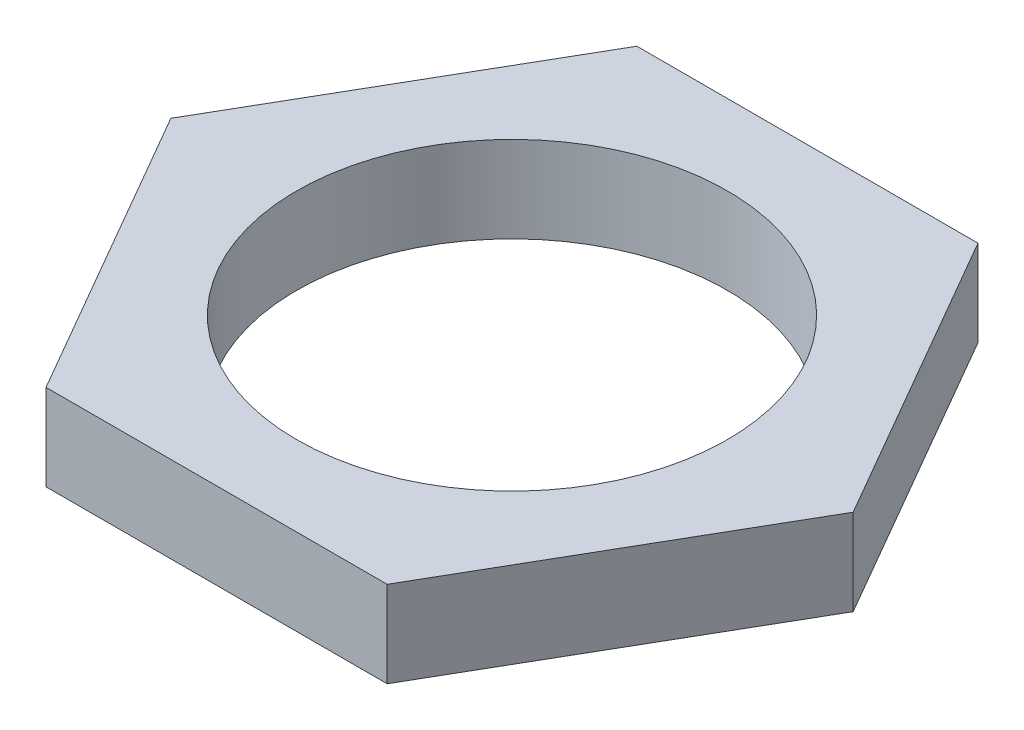
from build123d import *

# Parameters (mm, degrees)
SKETCH3_R           = 8.75
BOSS_EXTRUDE2_DEPTH = 3.5


with BuildPart() as part:
    # Sketch3 → Boss-Extrude2 (new body)
    with BuildSketch(Plane(origin=(0, 0, 0), x_dir=(1, 0, 0), z_dir=(0, 1, 0))):
        Polygon((-6.92820323, -12), (6.92820323, -12), (13.856406461, 0), (6.92820323, 12), (-6.92820323, 12), (-13.856406461, 0), align=None)
        Circle(SKETCH3_R, mode=Mode.SUBTRACT)
    extrude(amount=BOSS_EXTRUDE2_DEPTH)


solid = part.part
